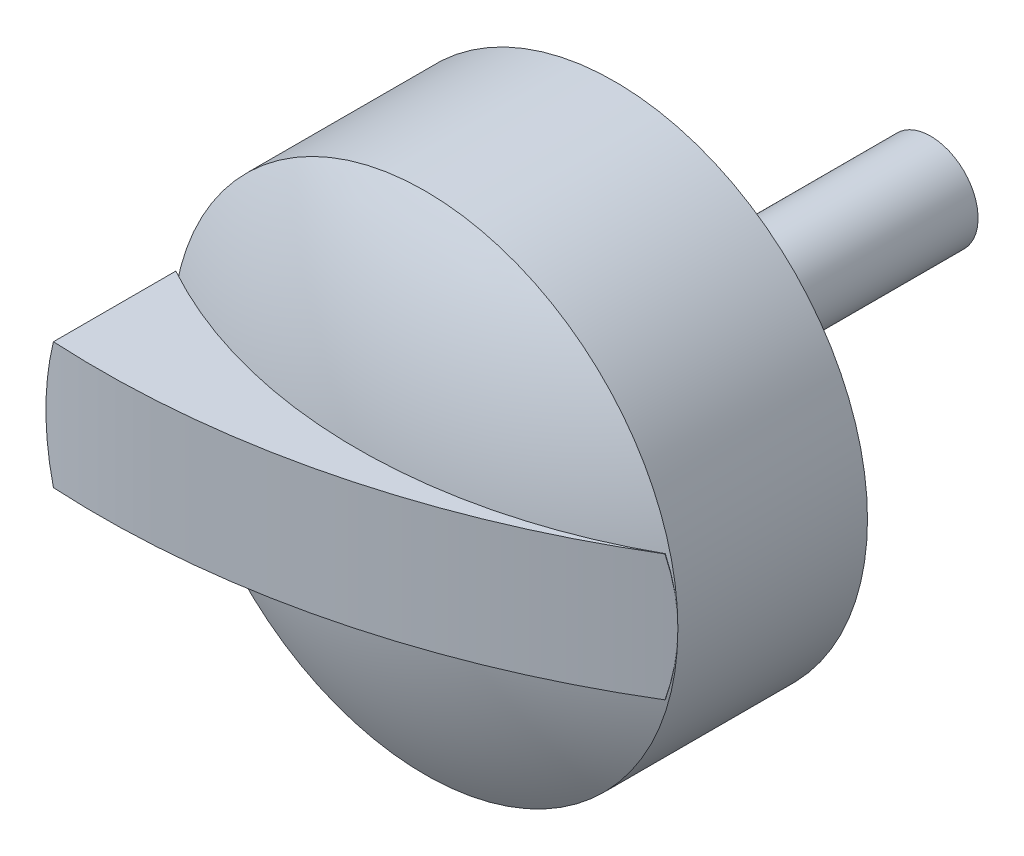
from build123d import *

# Parameters (mm, degrees)
SKETCH1_R                = 4.5
BOSS_EXTRUDE1_DEPTH      = 6
SKETCH1_R_2              = 8
SKETCH1_R_3              = 7.5
BOSS_EXTRUDE1_2_DEPTH    = 6
SKETCH8_R                = 1.5
BOSS_EXTRUDE3_DEPTH      = 10
BOSS_EXTRUDE4_DEPTH      = 2
BOSS_EXTRUDE4_DEPTH_BACK = 2
CUT_EXTRUDE1_DEPTH       = 2
CUT_EXTRUDE1_DEPTH_BACK  = 15
SKETCH10_R               = 8.273287204
SKETCH10_R_2             = 8


with BuildPart() as part:
    # Sketch1 → Boss-Extrude1 (new body)
    with BuildSketch(Plane.XY):
        Circle(SKETCH1_R)
    extrude(amount=BOSS_EXTRUDE1_DEPTH)



with BuildPart() as body_2:
    # Sketch1 → Boss-Extrude1 2 (new body)
    with BuildSketch(Plane.XY):
        Circle(SKETCH1_R_2)
        Circle(SKETCH1_R_3, mode=Mode.SUBTRACT)
    extrude(amount=BOSS_EXTRUDE1_2_DEPTH)


with BuildPart() as part_1:
    add(part.part)

    add(body_2.part)  # Revolve1 merges body 2
    # Sketch4 → Revolve1 (revolve)
    with BuildSketch(Plane(origin=(0, 0, 0), x_dir=(0, 0, -1), z_dir=(1, 0, 0))):
        with BuildLine():
            Line((-8.143593539, 0), (-6, 0))
            Line((-6, 0), (-6, -8))
            ThreePointArc((-6, -8), (-7.59840676, -4.141104722), (-8.143593539, 0))
        make_face()
    revolve(axis=Axis((0, 0, 228.477181529), (0, 0, -1)))

    # Sketch8 → Boss-Extrude3 (add)
    with BuildSketch(Plane(origin=(0, 0, 0), x_dir=(-1, 0, 0), z_dir=(0, 0, -1))):
        Circle(SKETCH8_R)
    extrude(amount=BOSS_EXTRUDE3_DEPTH)


with BuildPart() as body_2_2:
    # Sketch9 → Boss-Extrude4 (new, two sides: drawn at the far end of the back side and taken through both)
    with BuildSketch(Plane(origin=(0, 0, 0), x_dir=(1, 0, 0), z_dir=(0, 1, 0)).offset(-BOSS_EXTRUDE4_DEPTH_BACK)):
        with BuildLine():
            Line((-8, -6), (-8, -10))
            ThreePointArc((-8, -10), (0.312890295, -9.25156118), (8, -6))
            ThreePointArc((8, -6), (0, -8.143593539), (-8, -6))
        make_face()
    extrude(amount=BOSS_EXTRUDE4_DEPTH + BOSS_EXTRUDE4_DEPTH_BACK)

    # Sketch10 → Cut-Extrude1 (cut, two sides: drawn at the far end of the back side and taken through both)
    with BuildSketch(Plane.XY.offset(10).offset(-CUT_EXTRUDE1_DEPTH_BACK)):
        Circle(SKETCH10_R)
        Circle(SKETCH10_R_2, mode=Mode.SUBTRACT)
    extrude(amount=CUT_EXTRUDE1_DEPTH + CUT_EXTRUDE1_DEPTH_BACK, mode=Mode.SUBTRACT)


solid = Compound([part_1.part, body_2_2.part])
